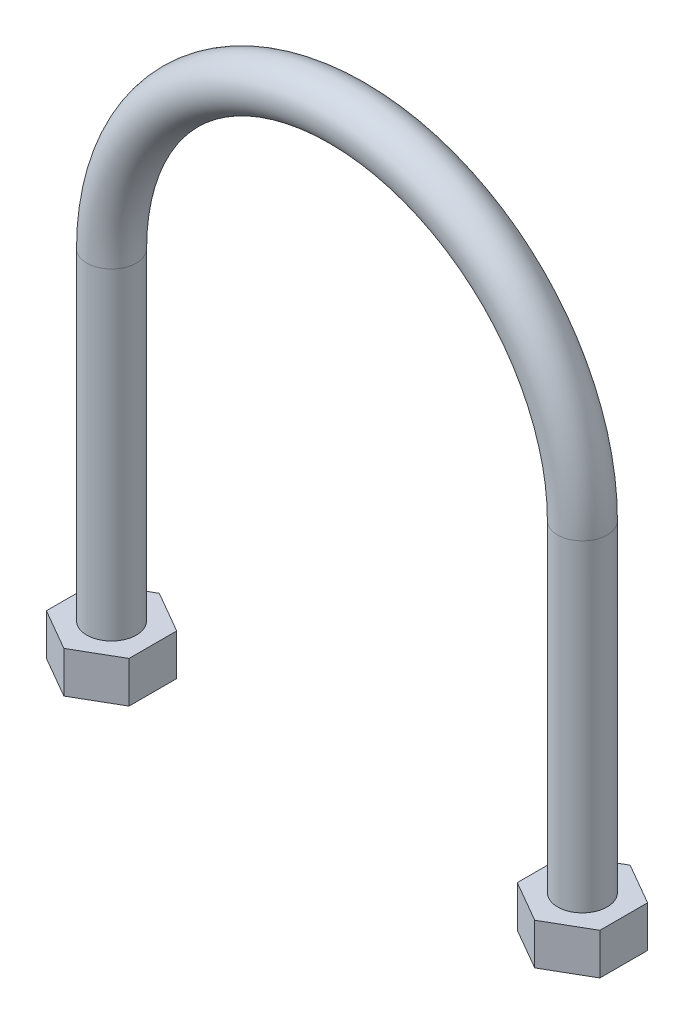
from build123d import *

# Parameters (mm, degrees)
SWEEP1_PROFILE_R    = 3
BOSS_EXTRUDE1_DEPTH = 5


with BuildPart() as part:
    # Sweep1: sweep along a path in Sketch1
    with BuildLine(Plane.XY) as sweep1_path:
        Line((-28.5, -42.5), (-28.5, 0))
        ThreePointArc((-28.5, 0), (0, 28.5), (28.5, 0))
        Line((28.5, 0), (28.5, -42.5))
    # Sweep1 profile (on start of the path) → Sweep1 (sweep)
    with BuildSketch(Plane(origin=(-28.5, -42.5, 0), x_dir=(1, 0, 0), z_dir=(0, 1, 0))):
        Circle(SWEEP1_PROFILE_R)
    sweep(path=sweep1_path.line)

    # Sketch14 → Boss-Extrude1 (add)
    with BuildSketch(Plane(origin=(0, -39, 0), x_dir=(1, 0, 0), z_dir=(0, 1, 0))):
        Polygon((-28.5, 5.773502692), (-33.5, 2.886751346), (-33.5, -2.886751346), (-28.5, -5.773502692), (-23.5, -2.886751346), (-23.5, 2.886751346), align=None)
        Polygon((23.5, 2.886751346), (28.5, 5.773502692), (33.5, 2.886751346), (33.5, -2.886751346), (28.5, -5.773502692), (23.5, -2.886751346), align=None)
    extrude(amount=-BOSS_EXTRUDE1_DEPTH)


solid = part.part
